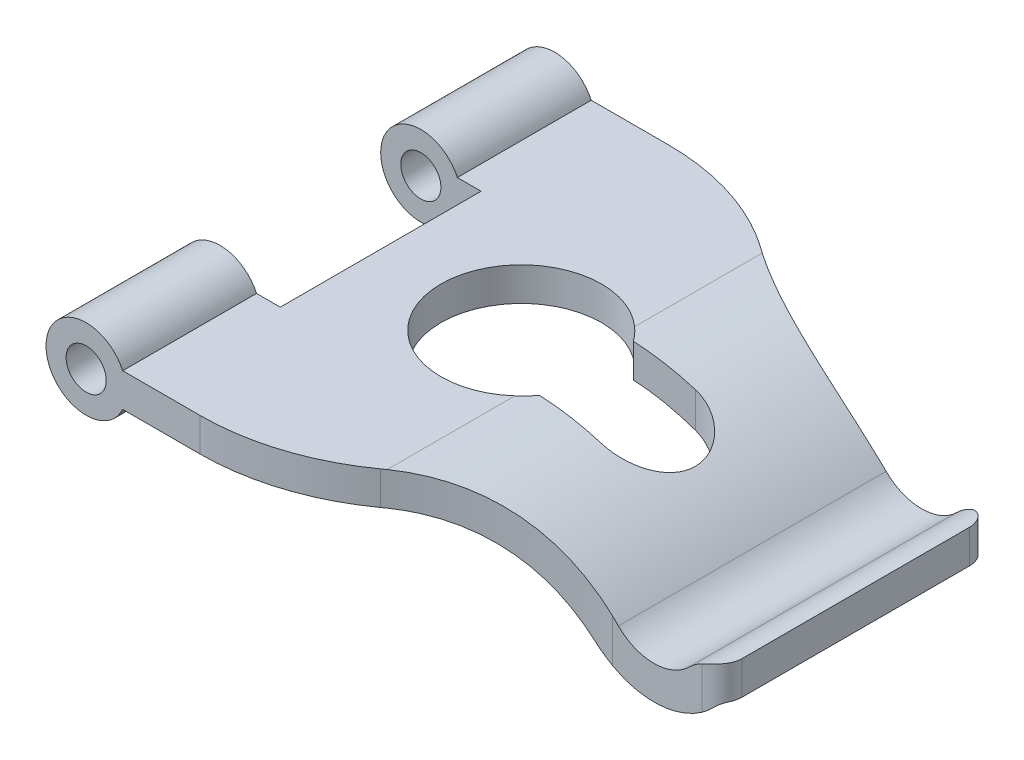
from build123d import *

# Parameters (mm, degrees)
SKETCH1_R               = 3
BOSS_EXTRUDE1_DEPTH     = 35
SKETCH2_W               = 15
SKETCH2_H               = 30
CUT_EXTRUDE2_DEPTH      = 4.5
CUT_EXTRUDE2_DEPTH_BACK = 19.180194847
CUT_EXTRUDE3_DEPTH      = 4.5
CUT_EXTRUDE3_DEPTH_BACK = 19.180194847
CUT_EXTRUDE5_DEPTH      = 4.5
CUT_EXTRUDE5_DEPTH_BACK = 19.180194847
FILLET2_R               = 3


with BuildPart() as part:
    # Sketch1 → Boss-Extrude1 (new body, symmetric)
    with BuildSketch(Plane.XY):
        with BuildLine():
            Line((6, -2.5), (38, -2.5))
            ThreePointArc((38, -2.5), (50.437211552, -4.973915193), (60.980970389, -12.019029611))
            ThreePointArc((60.980970389, -12.019029611), (69.818490023, -15.680194777), (78.656779847, -12.020889292))
            ThreePointArc((78.656779847, -12.020889292), (79.273086166, -11.609227247), (80, -11.464674847))
            Line((80, -11.464674847), (80, -6.464674847))
            ThreePointArc((80, -6.464674847), (77.360155024, -6.989628298), (75.121989969, -8.484611514))
            ThreePointArc((75.121989969, -8.484611514), (69.819016075, -10.680194805), (64.516504294, -8.483495706))
            ThreePointArc((64.516504294, -8.483495706), (52.350628714, -0.354517531), (38, 2.5))
            Line((38, 2.5), (6, 2.5))
            Line((6, 2.5), (5.454356057, 2.5))
            ThreePointArc((5.454356057, 2.5), (-6, 0), (5.454356057, -2.5))
            Line((5.454356057, -2.5), (6, -2.5))
        make_face()
        Circle(SKETCH1_R, mode=Mode.SUBTRACT)
    extrude(amount=BOSS_EXTRUDE1_DEPTH, both=True)

    # Sketch2 → Cut-Extrude2 (cut, two sides)
    with BuildSketch(Plane(origin=(0, 2.5, 0), x_dir=(1, 0, 0), z_dir=(0, 1, 0))) as cut_extrude2_sk:
        with Locations((1.5, 0)):
            Rectangle(SKETCH2_W, SKETCH2_H)
    extrude(amount=CUT_EXTRUDE2_DEPTH, mode=Mode.SUBTRACT)
    extrude(cut_extrude2_sk.sketch, amount=-CUT_EXTRUDE2_DEPTH_BACK, mode=Mode.SUBTRACT)

    # Sketch3 → Cut-Extrude3 (cut, two sides)
    with BuildSketch(Plane(origin=(0, 2.5, 0), x_dir=(1, 0, 0), z_dir=(0, 1, 0))) as cut_extrude3_sk:
        with BuildLine():
            Line((39.746794345, 7), (49, 7))
            ThreePointArc((49, 7), (56, 0), (49, -7))
            Line((49, -7), (39.746794345, -7))
            ThreePointArc((39.746794345, -7), (18, 0), (39.746794345, 7))
        make_face()
    extrude(amount=CUT_EXTRUDE3_DEPTH, mode=Mode.SUBTRACT)
    extrude(cut_extrude3_sk.sketch, amount=-CUT_EXTRUDE3_DEPTH_BACK, mode=Mode.SUBTRACT)

    # Sketch4 → Cut-Extrude5 (cut, two sides)
    with BuildSketch(Plane(origin=(0, 2.5, 0), x_dir=(1, 0, 0), z_dir=(0, 1, 0))) as cut_extrude5_sk:
        with BuildLine():
            Line((80, -20), (63.636895265, -20))
            ThreePointArc((63.636895265, -20), (49.858515462, -22.16127628), (37.403641679, -28.4375))
            ThreePointArc((37.403641679, -28.4375), (27.716517625, -33.319007338), (17, -35))
            Line((17, -35), (80, -35))
            Line((80, -35), (80, -20))
        make_face()
        with BuildLine():
            Line((80, 20), (63.636895265, 20))
            ThreePointArc((63.636895265, 20), (49.858515462, 22.16127628), (37.403641679, 28.4375))
            ThreePointArc((37.403641679, 28.4375), (27.716517625, 33.319007338), (17, 35))
            Line((17, 35), (80, 35))
            Line((80, 35), (80, 20))
        make_face()
    extrude(amount=CUT_EXTRUDE5_DEPTH, mode=Mode.SUBTRACT)
    extrude(cut_extrude5_sk.sketch, amount=-CUT_EXTRUDE5_DEPTH_BACK, mode=Mode.SUBTRACT)

    # Fillet2
    fillet2_edges = [part.edges().sort_by_distance(p)[0] for p in [
        (80, -8.964674847, -20),
        (80, -8.964674847, 20),
    ]]
    fillet(fillet2_edges, radius=FILLET2_R)


solid = part.part
